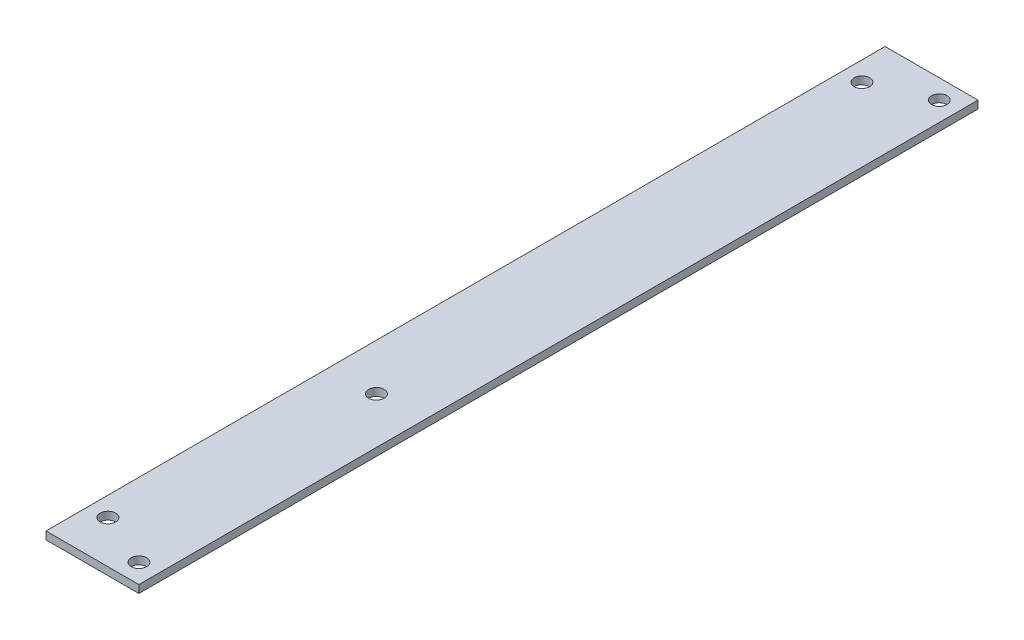
from build123d import *

# Parameters (mm, degrees)
SKETCH1_W               = 38.1
SKETCH1_H               = 3.175
BOSS_EXTRUDE1_DEPTH     = 344.17
SKETCH3_R               = 3.175
CUT_EXTRUDE1_DEPTH      = 4.175
SKETCH4_R               = 3.175
CUT_EXTRUDE2_DEPTH      = 1
CUT_EXTRUDE2_DEPTH_BACK = 4.175


with BuildPart() as part:
    # Sketch1 → Boss-Extrude1 (new body)
    with BuildSketch(Plane.XY):
        with Locations((19.05, 1.5875)):
            Rectangle(SKETCH1_W, SKETCH1_H)
    extrude(amount=BOSS_EXTRUDE1_DEPTH)

    # Sketch3 → Cut-Extrude1 (cut, through all)
    with BuildSketch(Plane(origin=(0, 3.175, 0), x_dir=(1, 0, 0), z_dir=(0, 1, 0))):
        with Locations((19.05, -227.7075202)):
            Circle(SKETCH3_R)
    extrude(amount=-CUT_EXTRUDE1_DEPTH, mode=Mode.SUBTRACT)

    # Sketch4 → Cut-Extrude2 (cut, two sides)
    with BuildSketch(Plane.XZ) as cut_extrude2_sk:
        with Locations((30.1625, 336.2325)):
            Circle(SKETCH4_R)
        with Locations((7.9375, 326.7075)):
            Circle(SKETCH4_R)
        with Locations((7.9375, 17.4625)):
            Circle(SKETCH4_R)
        with Locations((30.1625, 7.9375)):
            Circle(SKETCH4_R)
    extrude(amount=CUT_EXTRUDE2_DEPTH, mode=Mode.SUBTRACT)
    extrude(cut_extrude2_sk.sketch, amount=-CUT_EXTRUDE2_DEPTH_BACK, mode=Mode.SUBTRACT)


solid = part.part
